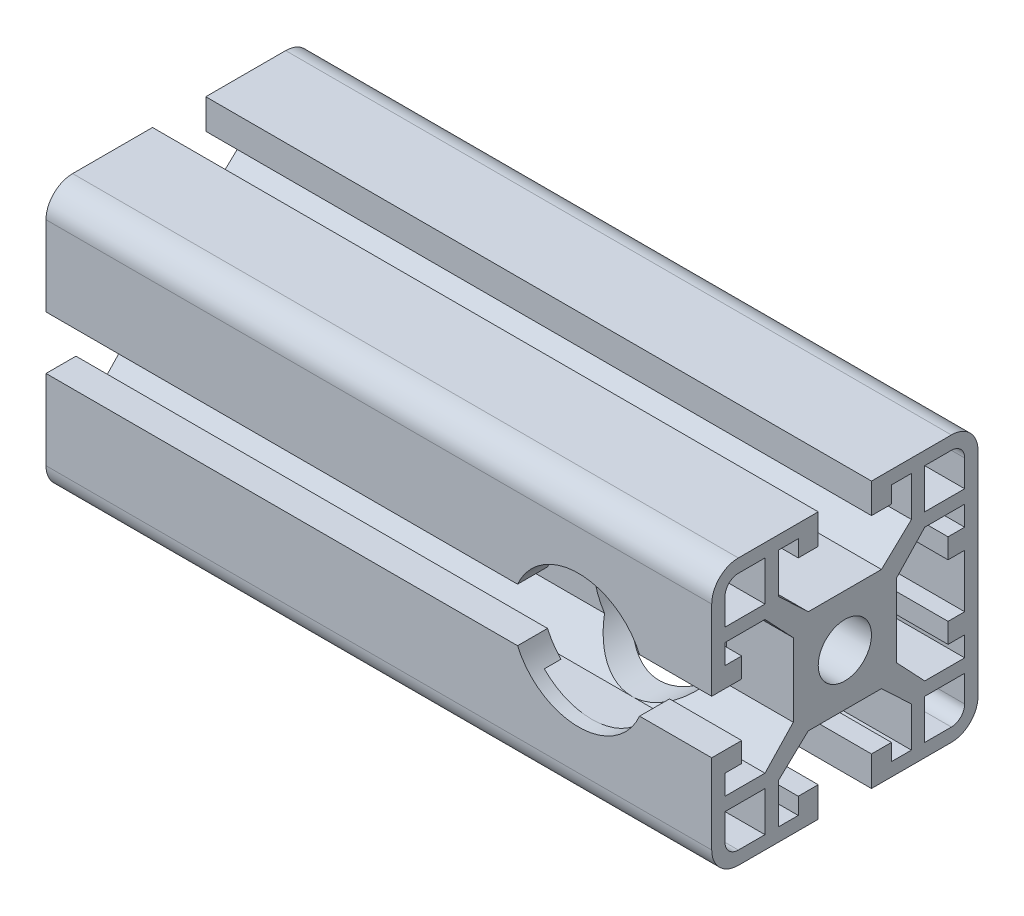
from build123d import *

# Parameters (mm, degrees)
SKIZZE11_R                     = 4
STRUKTURBAUTEIL1_DEPTH         = 100
SKIZZE2_R                      = 10
SCHNITT_LINEAR_AUSTRAGEN_DEPTH = 15.9


with BuildPart() as part:
    # Skizze11 → Strukturbauteil1 (new body)
    with BuildSketch(Plane(origin=(100, 0, 0), x_dir=(0, -1, 0), z_dir=(-1, 0, 0))):
        with BuildLine():
            Line((16, 20), (4, 20))
            Line((4, 20), (4, 15.5))
            Line((4, 15.5), (7, 15.5))
            Line((7, 15.5), (7, 18))
            Line((7, 18), (10, 18))
            Line((10, 18), (10, 12))
            Line((10, 12), (5.5, 7.75))
            Line((5.5, 7.75), (-5.5, 7.75))
            Line((-5.5, 7.75), (-10, 12))
            Line((-10, 12), (-10, 18))
            Line((-10, 18), (-7, 18))
            Line((-7, 18), (-7, 15.5))
            Line((-7, 15.5), (-4, 15.5))
            Line((-4, 15.5), (-4, 20))
            Line((-4, 20), (-16, 20))
            ThreePointArc((-16, 20), (-18.828427125, 18.828427125), (-20, 16))
            Line((-20, 16), (-20, 4))
            Line((-20, 4), (-15.5, 4))
            Line((-15.5, 4), (-15.5, 7))
            Line((-15.5, 7), (-18, 7))
            Line((-18, 7), (-18, 10))
            Line((-18, 10), (-12, 10))
            Line((-12, 10), (-7.75, 5.5))
            Line((-7.75, 5.5), (-7.75, -5.5))
            Line((-7.75, -5.5), (-12, -10))
            Line((-12, -10), (-18, -10))
            Line((-18, -10), (-18, -7))
            Line((-18, -7), (-15.5, -7))
            Line((-15.5, -7), (-15.5, -4))
            Line((-15.5, -4), (-20, -4))
            Line((-20, -4), (-20, -16))
            ThreePointArc((-20, -16), (-18.828427125, -18.828427125), (-16, -20))
            Line((-16, -20), (16, -20))
            ThreePointArc((16, -20), (18.828427125, -18.828427125), (20, -16))
            Line((20, -16), (20, -4))
            Line((20, -4), (15.5, -4))
            Line((15.5, -4), (15.5, -7))
            Line((15.5, -7), (18, -7))
            Line((18, -7), (18, -10))
            Line((18, -10), (12, -10))
            Line((12, -10), (7.75, -5.5))
            Line((7.75, -5.5), (7.75, 5.5))
            Line((7.75, 5.5), (12, 10))
            Line((12, 10), (18, 10))
            Line((18, 10), (18, 7))
            Line((18, 7), (15.5, 7))
            Line((15.5, 7), (15.5, 4))
            Line((15.5, 4), (20, 4))
            Line((20, 4), (20, 16))
            ThreePointArc((20, 16), (18.828427125, 18.828427125), (16, 20))
        make_face()
        Circle(SKIZZE11_R, mode=Mode.SUBTRACT)
        with BuildLine():
            Line((12, 18), (12, 12))
            Line((12, 12), (18, 12))
            Line((18, 12), (18, 16))
            ThreePointArc((18, 16), (17.414213562, 17.414213562), (16, 18))
            Line((16, 18), (12, 18))
        make_face(mode=Mode.SUBTRACT)
        with BuildLine():
            Line((-18, 12), (-12, 12))
            Line((-12, 12), (-12, 18))
            Line((-12, 18), (-16, 18))
            ThreePointArc((-16, 18), (-17.414213562, 17.414213562), (-18, 16))
            Line((-18, 16), (-18, 12))
        make_face(mode=Mode.SUBTRACT)
        Polygon((-4, -18), (4, -18), (4, -15.5), (7, -15.5), (7, -18), (10, -18), (10, -12), (5.5, -7.75), (-5.5, -7.75), (-10, -12), (-10, -18), (-7, -18), (-7, -15.5), (-4, -15.5), align=None, mode=Mode.SUBTRACT)
        with BuildLine():
            Line((18, -12), (12, -12))
            Line((12, -12), (12, -18))
            Line((12, -18), (16, -18))
            ThreePointArc((16, -18), (17.414213562, -17.414213562), (18, -16))
            Line((18, -16), (18, -12))
        make_face(mode=Mode.SUBTRACT)
        with BuildLine():
            Line((-12, -18), (-12, -12))
            Line((-12, -12), (-18, -12))
            Line((-18, -12), (-18, -16))
            ThreePointArc((-18, -16), (-17.414213562, -17.414213562), (-16, -18))
            Line((-16, -18), (-12, -18))
        make_face(mode=Mode.SUBTRACT)
    extrude(amount=STRUKTURBAUTEIL1_DEPTH)

    # Skizze2 → Schnitt-Linear austragen (cut)
    with BuildSketch(Plane(origin=(60.206991795, 21.446159487, 20), x_dir=(1, 0, 0), z_dir=(0, 0, 1))):
        with Locations(Location((19.793008205, -21.446159487, 0), (0, 0, 33.367012969))):  # turned: the seam where the file's is
            Circle(SKIZZE2_R)
    extrude(amount=-SCHNITT_LINEAR_AUSTRAGEN_DEPTH, mode=Mode.SUBTRACT)


solid = part.part
